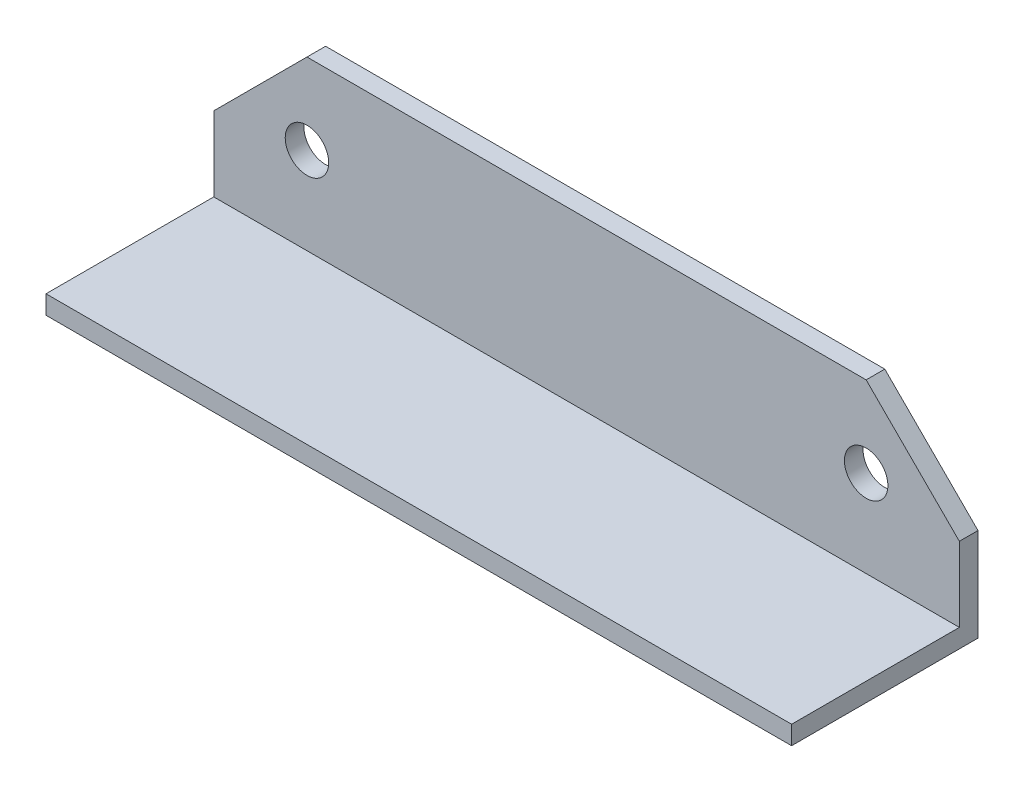
from build123d import *

# Parameters (mm, degrees)
SALIENTE_EXTRUIR1_DEPTH           = 3
CROQUIS2_W                        = 120
CROQUIS2_H                        = 3
SALIENTE_EXTRUIR2_DEPTH           = 27
DI_METRO_DE_TALADRO_7_0_7_1_D     = 7
DI_METRO_DE_TALADRO_7_0_7_1_DEPTH = 30


with BuildPart() as part:
    # Croquis1 → Saliente-Extruir1 (new body)
    with BuildSketch(Plane.XY.offset(-77.120136034)):
        Polygon((-60, 662.649987793), (-60, 647.649987793), (60, 647.649987793), (60, 662.649987793), (45, 677.649987793), (-45, 677.649987793), align=None)
    extrude(amount=-SALIENTE_EXTRUIR1_DEPTH)

    # Croquis2 → Saliente-Extruir2 (add)
    with BuildSketch(Plane.XY.offset(-77.120136034)):
        with Locations((0, 649.149987793)):
            Rectangle(CROQUIS2_W, CROQUIS2_H)
    extrude(amount=SALIENTE_EXTRUIR2_DEPTH)

    # Diámetro de taladro Ø7.0 (7)1
    with Locations(Plane(origin=(0, 0, -80.120136034), x_dir=(-1, 0, 0), z_dir=(0, 0, -1))):
        with Locations((45, 664.649987793), (-45, 664.649987793)):
            Hole(DI_METRO_DE_TALADRO_7_0_7_1_D / 2, depth=DI_METRO_DE_TALADRO_7_0_7_1_DEPTH)


solid = part.part
